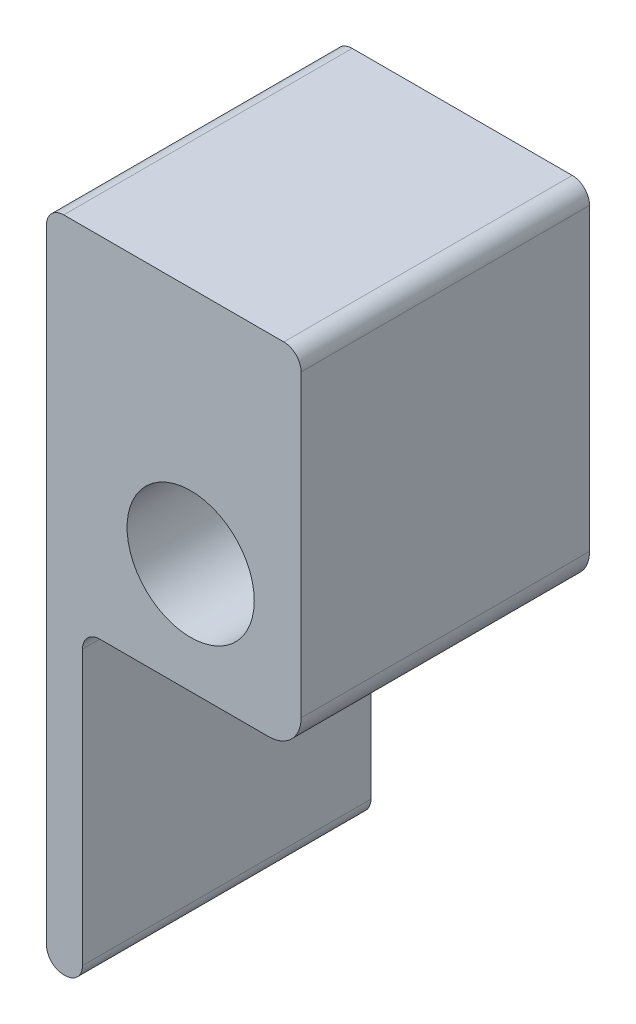
from build123d import *

# Parameters (mm, degrees)
SKETCH1_R           = 11.2
BOSS_EXTRUDE1_DEPTH = 50.8


with BuildPart() as part:
    # Sketch1 → Boss-Extrude1 (new body)
    with BuildSketch(Plane.XY):
        with BuildLine():
            Line((-25.4, -19.455), (-25.4, 19.455))
            Line((-25.4, 19.455), (-25.4, 39.031999962))
            ThreePointArc((-25.4, 39.031999962), (-24.507261469, 41.187261431), (-22.352, 42.079999962))
            Line((-22.352, 42.079999962), (16.407, 42.079999962))
            ThreePointArc((16.407, 42.079999962), (18.562261469, 41.187261431), (19.455, 39.031999962))
            Line((19.455, 39.031999962), (19.455, 19.455))
            Line((19.455, 19.455), (19.455, 0))
            Line((19.455, 0), (19.455, -13.74))
            ThreePointArc((19.455, -13.74), (17.781115254, -17.781115254), (13.74, -19.455))
            Line((13.74, -19.455), (0, -19.455))
            Line((0, -19.455), (-16.002, -19.455))
            ThreePointArc((-16.002, -19.455), (-18.157261469, -20.347738531), (-19.05, -22.503))
            Line((-19.05, -22.503), (-19.05, -70.781999962))
            ThreePointArc((-19.05, -70.781999962), (-19.942738531, -72.937261431), (-22.098, -73.829999962))
            Line((-22.098, -73.829999962), (-22.352, -73.829999962))
            ThreePointArc((-22.352, -73.829999962), (-24.507261469, -72.937261431), (-25.4, -70.781999962))
            Line((-25.4, -70.781999962), (-25.4, -19.455))
        make_face()
        Circle(SKETCH1_R, mode=Mode.SUBTRACT)
    extrude(amount=BOSS_EXTRUDE1_DEPTH)


solid = part.part
